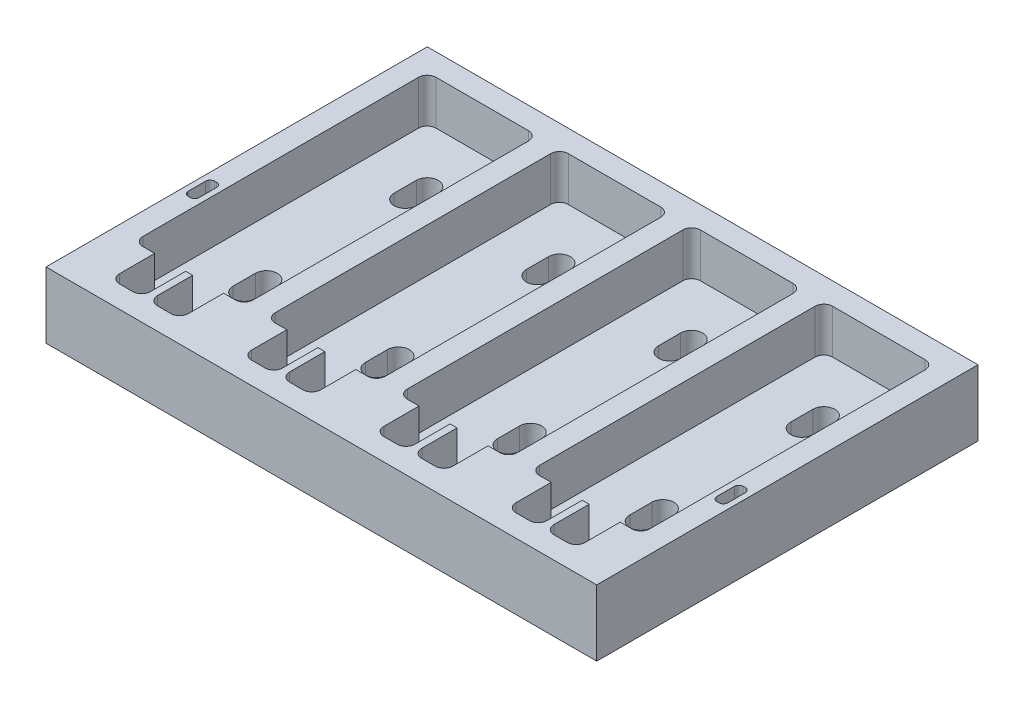
from build123d import *

# Parameters (mm, degrees)
SKETCH3_W           = 158.75
SKETCH3_H           = 109.9058
BOSS_EXTRUDE4_DEPTH = 19.05
CUT_EXTRUDE7_DEPTH  = 12.7
CUT_EXTRUDE8_DEPTH  = 194.499708976
CUT_EXTRUDE9_DEPTH  = 5.08


with BuildPart() as part:
    # Sketch3 → Boss-Extrude4 (new body)
    with BuildSketch(Plane(origin=(0, 0, 0), x_dir=(1, 0, 0), z_dir=(0, 1, 0))):
        with Locations((79.375, 54.9529)):
            Rectangle(SKETCH3_W, SKETCH3_H)
    extrude(amount=-BOSS_EXTRUDE4_DEPTH)

    # Sketch3_12 → Cut-Extrude7 (cut)
    with BuildSketch(Plane(origin=(0, 0, 0), x_dir=(1, 0, 0), z_dir=(0, 1, 0))):
        with BuildLine():
            ThreePointArc((82.55, 21.59), (83.293948776, 19.793948776), (85.09, 19.05))
            Line((85.09, 19.05), (88.4842, 19.05))
            Line((88.4842, 19.05), (88.4842, 8.89))
            ThreePointArc((88.4842, 8.89), (89.228148776, 7.093948776), (91.0242, 6.35))
            Line((91.0242, 6.35), (94.885, 6.35))
            ThreePointArc((94.885, 6.35), (96.681051224, 7.093948776), (97.425, 8.89))
            Line((97.425, 8.89), (97.425, 19.05))
            Line((97.425, 19.05), (99.425, 19.05))
            Line((99.425, 19.05), (99.425, 8.89))
            ThreePointArc((99.425, 8.89), (100.168948776, 7.093948776), (101.965, 6.35))
            Line((101.965, 6.35), (105.8258, 6.35))
            ThreePointArc((105.8258, 6.35), (107.621851224, 7.093948776), (108.3658, 8.89))
            Line((108.3658, 8.89), (108.3658, 19.05))
            Line((108.3658, 19.05), (111.76, 19.05))
            ThreePointArc((111.76, 19.05), (113.556051224, 19.793948776), (114.3, 21.59))
            Line((114.3, 21.59), (114.3, 101.0158))
            ThreePointArc((114.3, 101.0158), (113.556051224, 102.811851224), (111.76, 103.5558))
            Line((111.76, 103.5558), (85.09, 103.5558))
            ThreePointArc((85.09, 103.5558), (83.293948776, 102.811851224), (82.55, 101.0158))
            Line((82.55, 101.0158), (82.55, 21.59))
        make_face()
        with BuildLine():
            Line((6.35, 101.0158), (6.35, 21.59))
            ThreePointArc((6.35, 21.59), (7.093948776, 19.793948776), (8.89, 19.05))
            Line((8.89, 19.05), (12.2842, 19.05))
            Line((12.2842, 19.05), (12.2842, 8.89))
            ThreePointArc((12.2842, 8.89), (13.028148776, 7.093948776), (14.8242, 6.35))
            Line((14.8242, 6.35), (18.685, 6.35))
            ThreePointArc((18.685, 6.35), (20.481051224, 7.093948776), (21.225, 8.89))
            Line((21.225, 8.89), (21.225, 19.05))
            Line((21.225, 19.05), (23.225, 19.05))
            Line((23.225, 19.05), (23.225, 8.89))
            ThreePointArc((23.225, 8.89), (23.968948776, 7.093948776), (25.765, 6.35))
            Line((25.765, 6.35), (29.6258, 6.35))
            ThreePointArc((29.6258, 6.35), (31.421851224, 7.093948776), (32.1658, 8.89))
            Line((32.1658, 8.89), (32.1658, 19.05))
            Line((32.1658, 19.05), (35.56, 19.05))
            ThreePointArc((35.56, 19.05), (37.356051224, 19.793948776), (38.1, 21.59))
            Line((38.1, 21.59), (38.1, 101.0158))
            ThreePointArc((38.1, 101.0158), (37.356051224, 102.811851224), (35.56, 103.5558))
            Line((35.56, 103.5558), (8.89, 103.5558))
            ThreePointArc((8.89, 103.5558), (7.093948776, 102.811851224), (6.35, 101.0158))
        make_face()
        with BuildLine():
            ThreePointArc((46.99, 103.5558), (45.193948776, 102.811851224), (44.45, 101.0158))
            Line((44.45, 101.0158), (44.45, 21.59))
            ThreePointArc((44.45, 21.59), (45.193948776, 19.793948776), (46.99, 19.05))
            Line((46.99, 19.05), (50.3842, 19.05))
            Line((50.3842, 19.05), (50.3842, 8.89))
            ThreePointArc((50.3842, 8.89), (51.128148776, 7.093948776), (52.9242, 6.35))
            Line((52.9242, 6.35), (56.785, 6.35))
            ThreePointArc((56.785, 6.35), (58.581051224, 7.093948776), (59.325, 8.89))
            Line((59.325, 8.89), (59.325, 19.05))
            Line((59.325, 19.05), (61.325, 19.05))
            Line((61.325, 19.05), (61.325, 8.89))
            ThreePointArc((61.325, 8.89), (62.068948776, 7.093948776), (63.865, 6.35))
            Line((63.865, 6.35), (67.7258, 6.35))
            ThreePointArc((67.7258, 6.35), (69.521851224, 7.093948776), (70.2658, 8.89))
            Line((70.2658, 8.89), (70.2658, 19.05))
            Line((70.2658, 19.05), (73.66, 19.05))
            ThreePointArc((73.66, 19.05), (75.456051224, 19.793948776), (76.2, 21.59))
            Line((76.2, 21.59), (76.2, 101.0158))
            ThreePointArc((76.2, 101.0158), (75.456051224, 102.811851224), (73.66, 103.5558))
            Line((73.66, 103.5558), (46.99, 103.5558))
        make_face()
        with BuildLine():
            ThreePointArc((120.65, 21.59), (121.393948776, 19.793948776), (123.19, 19.05))
            Line((123.19, 19.05), (126.5842, 19.05))
            Line((126.5842, 19.05), (126.5842, 8.89))
            ThreePointArc((126.5842, 8.89), (127.328148776, 7.093948776), (129.1242, 6.35))
            Line((129.1242, 6.35), (132.985, 6.35))
            ThreePointArc((132.985, 6.35), (134.781051224, 7.093948776), (135.525, 8.89))
            Line((135.525, 8.89), (135.525, 19.05))
            Line((135.525, 19.05), (137.525, 19.05))
            Line((137.525, 19.05), (137.525, 8.89))
            ThreePointArc((137.525, 8.89), (138.268948776, 7.093948776), (140.065, 6.35))
            Line((140.065, 6.35), (143.9258, 6.35))
            ThreePointArc((143.9258, 6.35), (145.721851224, 7.093948776), (146.4658, 8.89))
            Line((146.4658, 8.89), (146.4658, 19.05))
            Line((146.4658, 19.05), (149.86, 19.05))
            ThreePointArc((149.86, 19.05), (151.656051224, 19.793948776), (152.4, 21.59))
            Line((152.4, 21.59), (152.4, 101.0158))
            ThreePointArc((152.4, 101.0158), (151.656051224, 102.811851224), (149.86, 103.5558))
            Line((149.86, 103.5558), (123.19, 103.5558))
            ThreePointArc((123.19, 103.5558), (121.393948776, 102.811851224), (120.65, 101.0158))
            Line((120.65, 101.0158), (120.65, 21.59))
        make_face()
    extrude(amount=-CUT_EXTRUDE7_DEPTH, mode=Mode.SUBTRACT)

    # Sketch5 → Cut-Extrude8 (cut, through all)
    with BuildSketch(Plane(origin=(0, -12.7, 0), x_dir=(1, 0, 0), z_dir=(0, 1, 0))):
        with BuildLine():
            Line((25.4, 87.6808), (25.4, 81.3308))
            ThreePointArc((25.4, 81.3308), (22.225, 78.1558), (19.05, 81.3308))
            Line((19.05, 81.3308), (19.05, 87.6808))
            ThreePointArc((19.05, 87.6808), (22.225, 90.8558), (25.4, 87.6808))
        make_face()
        with BuildLine():
            Line((25.4, 41.275), (25.4, 34.925))
            ThreePointArc((25.4, 34.925), (22.225, 31.75), (19.05, 34.925))
            Line((19.05, 34.925), (19.05, 41.275))
            ThreePointArc((19.05, 41.275), (22.225, 44.45), (25.4, 41.275))
        make_face()
        with BuildLine():
            Line((57.15, 34.925), (57.15, 41.275))
            ThreePointArc((57.15, 41.275), (60.325, 44.45), (63.5, 41.275))
            Line((63.5, 41.275), (63.5, 34.925))
            ThreePointArc((63.5, 34.925), (60.325, 31.75), (57.15, 34.925))
        make_face()
        with BuildLine():
            Line((57.15, 81.3308), (57.15, 87.6808))
            ThreePointArc((57.15, 87.6808), (60.325, 90.8558), (63.5, 87.6808))
            Line((63.5, 87.6808), (63.5, 81.3308))
            ThreePointArc((63.5, 81.3308), (60.325, 78.1558), (57.15, 81.3308))
        make_face()
        with BuildLine():
            Line((101.6, 87.6808), (101.6, 81.3308))
            ThreePointArc((101.6, 81.3308), (98.425, 78.1558), (95.25, 81.3308))
            Line((95.25, 81.3308), (95.25, 87.6808))
            ThreePointArc((95.25, 87.6808), (98.425, 90.8558), (101.6, 87.6808))
        make_face()
        with BuildLine():
            Line((101.6, 41.275), (101.6, 34.925))
            ThreePointArc((101.6, 34.925), (98.425, 31.75), (95.25, 34.925))
            Line((95.25, 34.925), (95.25, 41.275))
            ThreePointArc((95.25, 41.275), (98.425, 44.45), (101.6, 41.275))
        make_face()
        with BuildLine():
            Line((139.7, 41.275), (139.7, 34.925))
            ThreePointArc((139.7, 34.925), (136.525, 31.75), (133.35, 34.925))
            Line((133.35, 34.925), (133.35, 41.275))
            ThreePointArc((133.35, 41.275), (136.525, 44.45), (139.7, 41.275))
        make_face()
        with BuildLine():
            Line((139.7, 87.6808), (139.7, 81.3308))
            ThreePointArc((139.7, 81.3308), (136.525, 78.1558), (133.35, 81.3308))
            Line((133.35, 81.3308), (133.35, 87.6808))
            ThreePointArc((133.35, 87.6808), (136.525, 90.8558), (139.7, 87.6808))
        make_face()
    extrude(amount=-CUT_EXTRUDE8_DEPTH, mode=Mode.SUBTRACT)

    # Sketch7 → Cut-Extrude9 (cut)
    with BuildSketch(Plane(origin=(0, 0, 0), x_dir=(1, 0, 0), z_dir=(0, 1, 0))):
        with BuildLine():
            Line((2.8575, 45.72), (3.4925, 45.72))
            ThreePointArc((3.4925, 45.72), (4.390525612, 45.348025612), (4.7625, 44.45))
            Line((4.7625, 44.45), (4.7625, 39.37))
            ThreePointArc((4.7625, 39.37), (4.390525612, 38.471974388), (3.4925, 38.1))
            Line((3.4925, 38.1), (2.8575, 38.1))
            ThreePointArc((2.8575, 38.1), (1.959474388, 38.471974388), (1.5875, 39.37))
            Line((1.5875, 39.37), (1.5875, 44.45))
            ThreePointArc((1.5875, 44.45), (1.959474388, 45.348025612), (2.8575, 45.72))
        make_face()
        with BuildLine():
            Line((153.9875, 44.45), (153.9875, 39.37))
            ThreePointArc((153.9875, 39.37), (154.359474388, 38.471974388), (155.2575, 38.1))
            Line((155.2575, 38.1), (155.8925, 38.1))
            ThreePointArc((155.8925, 38.1), (156.790525612, 38.471974388), (157.1625, 39.37))
            Line((157.1625, 39.37), (157.1625, 44.45))
            ThreePointArc((157.1625, 44.45), (156.790525612, 45.348025612), (155.8925, 45.72))
            Line((155.8925, 45.72), (155.2575, 45.72))
            ThreePointArc((155.2575, 45.72), (154.359474388, 45.348025612), (153.9875, 44.45))
        make_face()
    extrude(amount=-CUT_EXTRUDE9_DEPTH, mode=Mode.SUBTRACT)


solid = part.part
